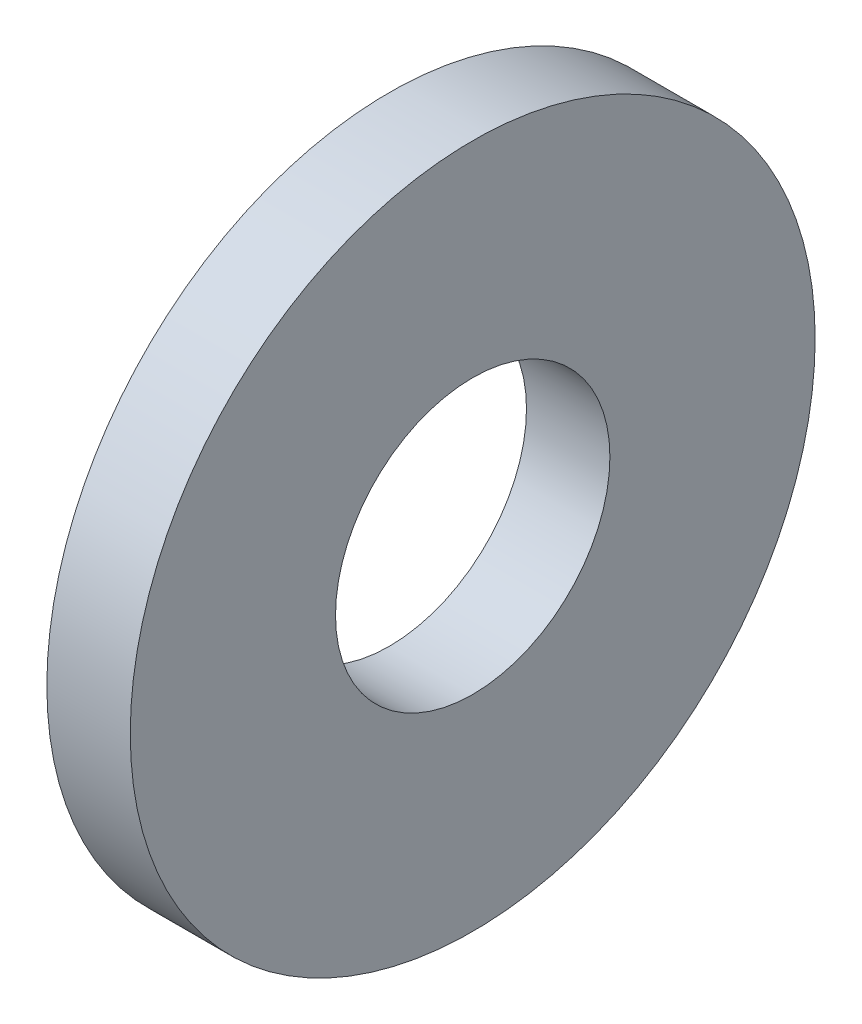
from build123d import *

# Parameters (mm, degrees)
SKETCH1_R           = 3.9624
SKETCH1_R_2         = 1.5875
BOSS_EXTRUDE1_DEPTH = 0.9652


with BuildPart() as part:
    # Sketch1 → Boss-Extrude1 (new body)
    with BuildSketch(Plane(origin=(0, 0, 0), x_dir=(0, 0, -1), z_dir=(1, 0, 0))):
        Circle(SKETCH1_R)
        Circle(SKETCH1_R_2, mode=Mode.SUBTRACT)
    extrude(amount=BOSS_EXTRUDE1_DEPTH)


solid = part.part
